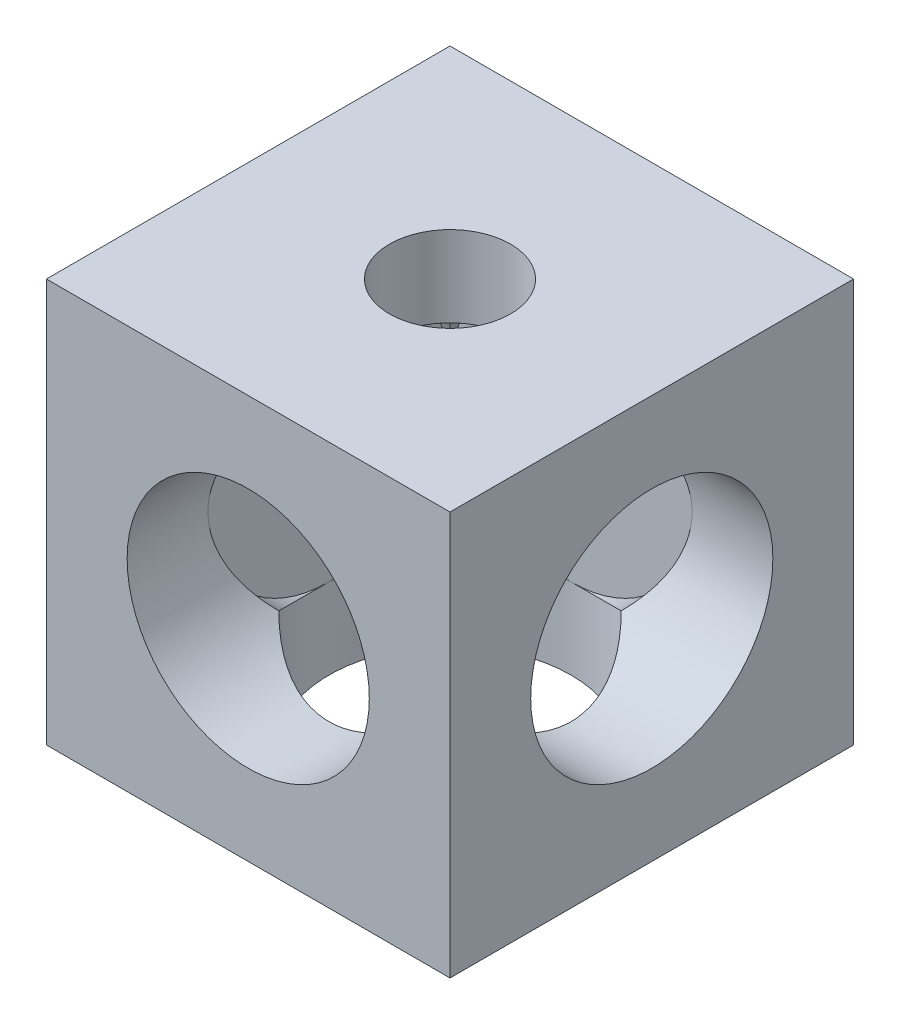
from build123d import *

# Parameters (mm, degrees)
ESQUISSE1_W             = 10
ESQUISSE1_H             = 10
BOSS_EXTRU_1_DEPTH      = 10
ESQUISSE2_R             = 1.5
ENL_V_MAT_EXTRU_1_DEPTH = 11
ESQUISSE3_R             = 3
ENL_V_MAT_EXTRU_2_DEPTH = 8
ESQUISSE4_R             = 1.5
ENL_V_MAT_EXTRU_3_DEPTH = 11
ESQUISSE5_R             = 3
ENL_V_MAT_EXTRU_4_DEPTH = 8
ESQUISSE6_R             = 1.5
ENL_V_MAT_EXTRU_5_DEPTH = 11
ESQUISSE7_R             = 3
ENL_V_MAT_EXTRU_6_DEPTH = 8


with BuildPart() as part:
    # Esquisse1 → Boss.-Extru.1 (new body)
    with BuildSketch(Plane.XY):
        with Locations((5, 5)):
            Rectangle(ESQUISSE1_W, ESQUISSE1_H)
    extrude(amount=BOSS_EXTRU_1_DEPTH)

    # Esquisse2 → Enlèv. mat.-Extru.1 (cut, through all)
    with BuildSketch(Plane.XY.offset(10)):
        with Locations((5, 5)):
            Circle(ESQUISSE2_R)
    extrude(amount=-ENL_V_MAT_EXTRU_1_DEPTH, mode=Mode.SUBTRACT)

    # Esquisse3 → Enlèv. mat.-Extru.2 (cut)
    with BuildSketch(Plane.XY.offset(10)):
        with Locations((5, 5)):
            Circle(ESQUISSE3_R)
    extrude(amount=-ENL_V_MAT_EXTRU_2_DEPTH, mode=Mode.SUBTRACT)

    # Esquisse4 → Enlèv. mat.-Extru.3 (cut, through all)
    with BuildSketch(Plane(origin=(10, 0, 0), x_dir=(0, 0, -1), z_dir=(1, 0, 0))):
        with Locations((-5, 5)):
            Circle(ESQUISSE4_R)
    extrude(amount=-ENL_V_MAT_EXTRU_3_DEPTH, mode=Mode.SUBTRACT)

    # Esquisse5 → Enlèv. mat.-Extru.4 (cut)
    with BuildSketch(Plane(origin=(10, 0, 0), x_dir=(0, 0, -1), z_dir=(1, 0, 0))):
        with Locations((-5, 5)):
            Circle(ESQUISSE5_R)
    extrude(amount=-ENL_V_MAT_EXTRU_4_DEPTH, mode=Mode.SUBTRACT)

    # Esquisse6 → Enlèv. mat.-Extru.5 (cut, through all)
    with BuildSketch(Plane.XZ):
        with Locations((5, 5)):
            Circle(ESQUISSE6_R)
    extrude(amount=-ENL_V_MAT_EXTRU_5_DEPTH, mode=Mode.SUBTRACT)

    # Esquisse7 → Enlèv. mat.-Extru.6 (cut)
    with BuildSketch(Plane(origin=(0, 0, 0), x_dir=(-1, 0, 0), z_dir=(0, -1, 0))):
        with Locations((-5, -5)):
            Circle(ESQUISSE7_R)
    extrude(amount=-ENL_V_MAT_EXTRU_6_DEPTH, mode=Mode.SUBTRACT)


solid = part.part
